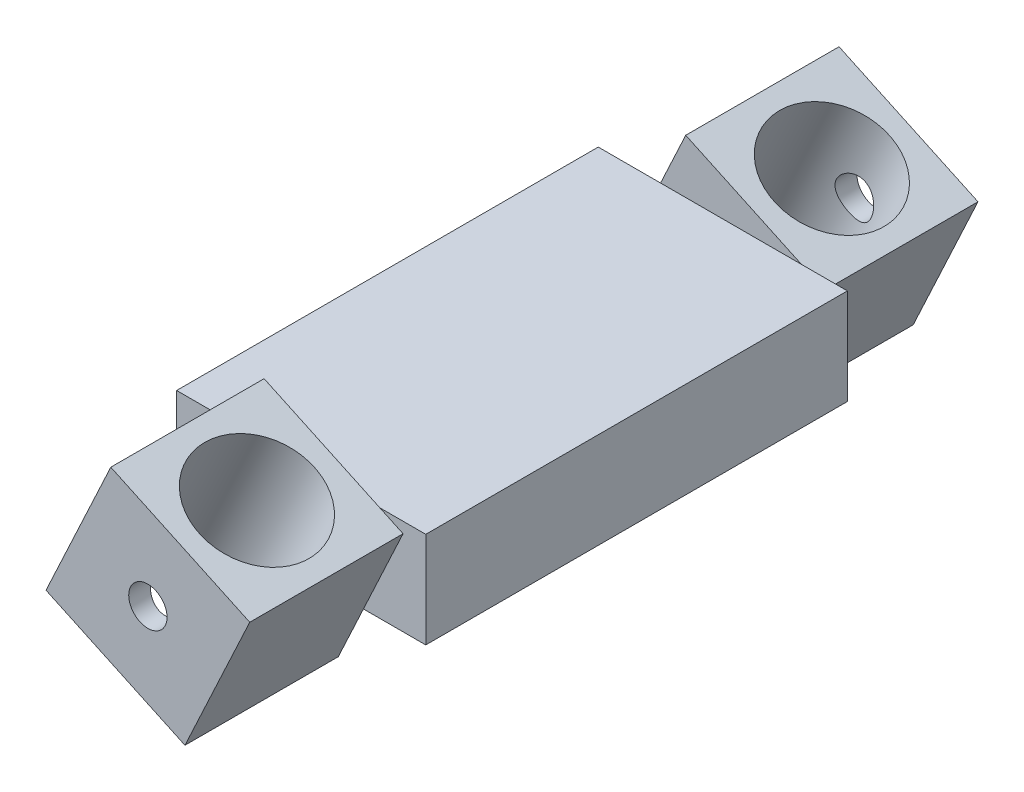
from build123d import *

# Parameters (mm, degrees)
BOSS_EXTRUDE1_DEPTH = 8
BOSS_EXTRUDE2_DEPTH = 11
BOSS_EXTRUDE3_DEPTH = 11
SKETCH5_R           = 1
CUT_EXTRUDE2_DEPTH  = 4
CUT_EXTRUDE1_REACH  = 13.565
SKETCH4_R           = 3


with BuildPart() as part:
    # Sketch1 → Boss-Extrude1 (new body)
    with BuildSketch(Plane.XY):
        Polygon((0, 0), (-7.250462296, 3.380946094), (-3.869516202, 10.63140839), (3.380946094, 7.250462296), align=None)
    extrude(amount=BOSS_EXTRUDE1_DEPTH)

    # Sketch2 → Boss-Extrude2 (add)
    with BuildSketch(Plane.XY.offset(8)):
        Polygon((-6.038297133, 2.815704195), (1.312984429, 2.815704195), (3.380946094, 7.250462296), (2.16878093, 7.815704195), (-5.182500632, 7.815704195), (-7.250462296, 3.380946094), align=None)
    extrude(amount=BOSS_EXTRUDE2_DEPTH)

    # Sketch3 → Boss-Extrude3 (add)
    with BuildSketch(Plane.XY.offset(8)):
        Polygon((-5.182500632, 7.815704195), (-8.434758101, 7.815704195), (-8.434758101, 2.815704195), (-6.038297133, 2.815704195), (-7.250462296, 3.380946094), align=None)
        Polygon((1.312984429, 2.815704195), (4.565241899, 2.815704195), (4.565241899, 7.815704195), (2.16878093, 7.815704195), (3.380946094, 7.250462296), align=None)
    extrude(amount=BOSS_EXTRUDE3_DEPTH)

    # Sketch5 → Cut-Extrude2 (cut)
    with BuildSketch(Plane(origin=(0, 0, 0), x_dir=(-1, 0, 0), z_dir=(0, 0, -1))):
        with Locations((1.934758101, 5.315704195)):
            Circle(SKETCH5_R)
    extrude(amount=-CUT_EXTRUDE2_DEPTH, mode=Mode.SUBTRACT)

    # Mirror2: part across face


with BuildPart() as part_1:
    add(part.part)
    add(part.part.mirror(Plane(origin=(-1.934758101, 5.315704195, 19), x_dir=(1, 0, 0), z_dir=(0, 0, 1))))

    # Sketch4 → Cut-Extrude1 (cut, up to next)
    with BuildSketch(Plane(origin=(3.380946094, 7.250462296, 0), x_dir=(0.906307787, -0.422618262, 0), z_dir=(0.422618262, 0.906307787, 0)), mode=Mode.PRIVATE) as cut_extrude1_sk1:
        with Locations((-4, -4)):
            Circle(SKETCH4_R)
    cut_extrude1_tool1 = extrude(cut_extrude1_sk1.sketch, amount=-CUT_EXTRUDE1_REACH, mode=Mode.PRIVATE) & part_1.part
    add(cut_extrude1_tool1.solids().sort_by_distance((-0.244285, 8.940935, 4))[0], mode=Mode.SUBTRACT)
    # Sketch4 → Cut-Extrude1 (cut, up to next)
    with BuildSketch(Plane(origin=(3.380946094, 7.250462296, 0), x_dir=(0.906307787, -0.422618262, 0), z_dir=(0.422618262, 0.906307787, 0)), mode=Mode.PRIVATE) as cut_extrude1_sk2:
        with Locations((-4, -34)):
            Circle(SKETCH4_R)
    cut_extrude1_tool2 = extrude(cut_extrude1_sk2.sketch, amount=-CUT_EXTRUDE1_REACH, mode=Mode.PRIVATE) & part_1.part
    add(cut_extrude1_tool2.solids().sort_by_distance((-0.244285, 8.940935, 34))[0], mode=Mode.SUBTRACT)


solid = part_1.part
